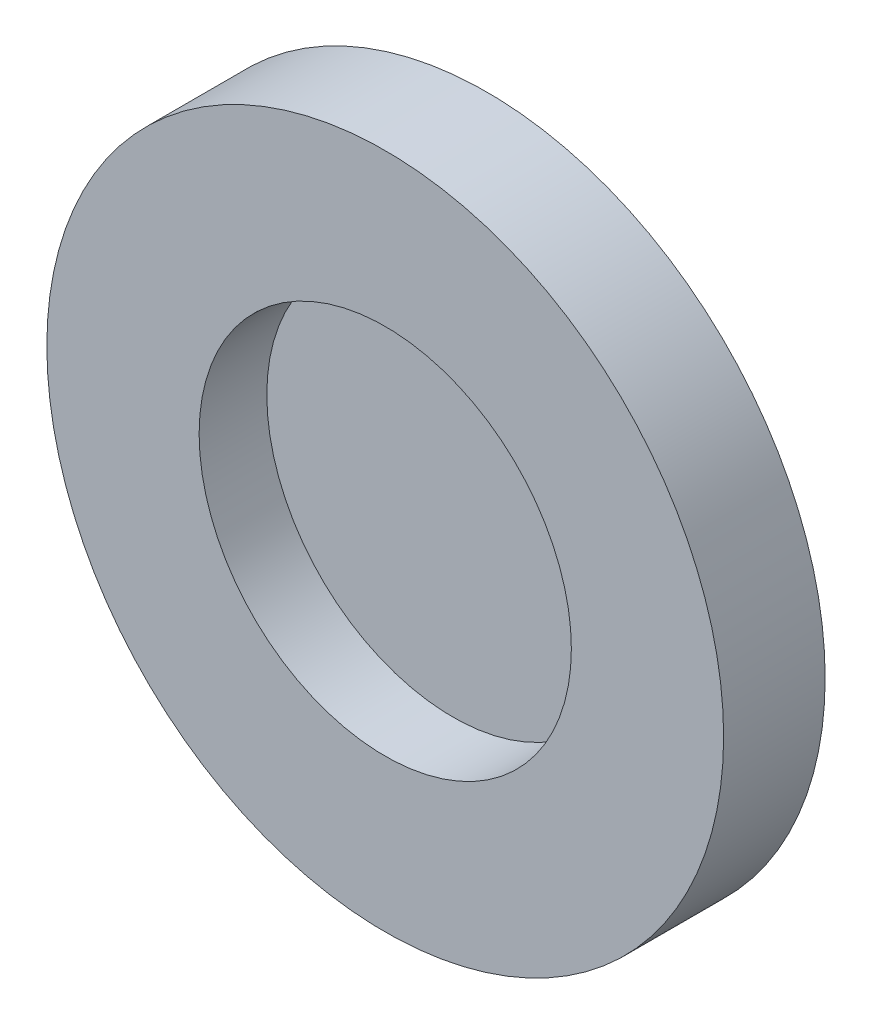
from build123d import *

# Parameters (mm, degrees)
SKETCH1_R           = 10
SKETCH1_R_2         = 5.5
BOSS_EXTRUDE1_DEPTH = 2
SKETCH2_R           = 10
BOSS_EXTRUDE2_DEPTH = 1


with BuildPart() as part:
    # Sketch1 → Boss-Extrude1 (new body)
    with BuildSketch(Plane.XY):
        Circle(SKETCH1_R)
        Circle(SKETCH1_R_2, mode=Mode.SUBTRACT)
    extrude(amount=BOSS_EXTRUDE1_DEPTH)

    # Sketch2 → Boss-Extrude2 (add)
    with BuildSketch(Plane(origin=(0, 0, 0), x_dir=(-1, 0, 0), z_dir=(0, 0, -1))):
        Circle(SKETCH2_R)
    extrude(amount=BOSS_EXTRUDE2_DEPTH)


solid = part.part
